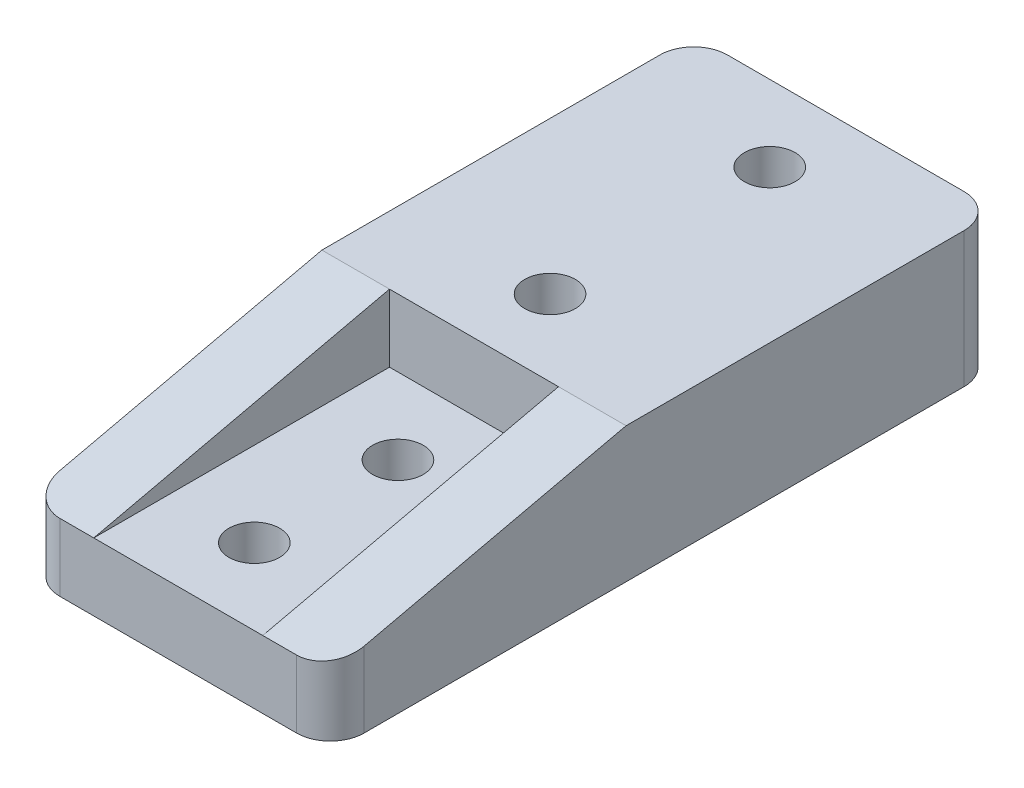
from build123d import *

# Parameters (mm, degrees)
SKETCH1_W      = 18
SKETCH1_H      = 39.5
EXTRUDE1_DEPTH = 8
SKETCH4_W      = 10
SKETCH4_H      = 17.5
EXTRUDE3_DEPTH = 4
EXTRUDE4_DEPTH = 35.234485537
SKETCH4_4_R    = 1.5
EXTRUDE5_DEPTH = 31.479501308
FILLET1_R      = 2
SKETCH8_R      = 1.5
EXTRUDE6_DEPTH = 30.681644159
SKETCH9_R      = 3.5
EXTRUDE7_DEPTH = 3
FILLET2_R      = 2


with BuildPart() as part:
    # Sketch1 → Extrude1 (new body)
    with BuildSketch(Plane(origin=(0, 0, 0), x_dir=(1, 0, 0), z_dir=(0, 1, 0))):
        with Locations((0, -8.25)):
            Rectangle(SKETCH1_W, SKETCH1_H)
    extrude(amount=EXTRUDE1_DEPTH)

    # Sketch4 → Extrude3 (cut)
    with BuildSketch(Plane(origin=(0, 8, 0), x_dir=(-1, 0, 0), z_dir=(0, 1, 0))):
        with Locations((0, 19.25)):
            Rectangle(SKETCH4_W, SKETCH4_H)
    extrude(amount=-EXTRUDE3_DEPTH, mode=Mode.SUBTRACT)

    # Sketch7 → Extrude4 (cut, through all)
    with BuildSketch(Plane(origin=(9, 0, 0), x_dir=(0, 0, -1), z_dir=(1, 0, 0))):
        Polygon((-28, 4), (-10.5, 8), (-28, 8), align=None)
    extrude(amount=-EXTRUDE4_DEPTH, mode=Mode.SUBTRACT)

    # Sketch4_4 → Extrude5 (cut, through all)
    with BuildSketch(Plane(origin=(0, 8, 0), x_dir=(-1, 0, 0), z_dir=(0, 1, 0))):
        with Locations((0, -7)):
            Circle(SKETCH4_4_R)
        with Locations((0, 6)):
            Circle(SKETCH4_4_R)
    extrude(amount=-EXTRUDE5_DEPTH, mode=Mode.SUBTRACT)

    # Fillet1
    fillet1_edges = [part.edges().sort_by_distance(p)[0] for p in [
        (-9, 2, 28),
        (9, 2, 28),
    ]]
    fillet(fillet1_edges, radius=FILLET1_R)

    # Sketch8 → Extrude6 (cut, through all)
    with BuildSketch(Plane(origin=(0, 4, 0), x_dir=(-1, 0, 0), z_dir=(0, 1, 0))):
        with Locations((0, 15)):
            Circle(SKETCH8_R)
        with Locations((0, 23.5)):
            Circle(SKETCH8_R)
    extrude(amount=-EXTRUDE6_DEPTH, mode=Mode.SUBTRACT)

    # Sketch9 → Extrude7 (cut)
    with BuildSketch(Plane.XZ):
        with Locations((0, 6)):
            Circle(SKETCH9_R)
    extrude(amount=-EXTRUDE7_DEPTH, mode=Mode.SUBTRACT)

    # Fillet2
    fillet2_edges = [part.edges().sort_by_distance(p)[0] for p in [
        (-9, 4, -11.5),
        (9, 4, -11.5),
    ]]
    fillet(fillet2_edges, radius=FILLET2_R)


solid = part.part
